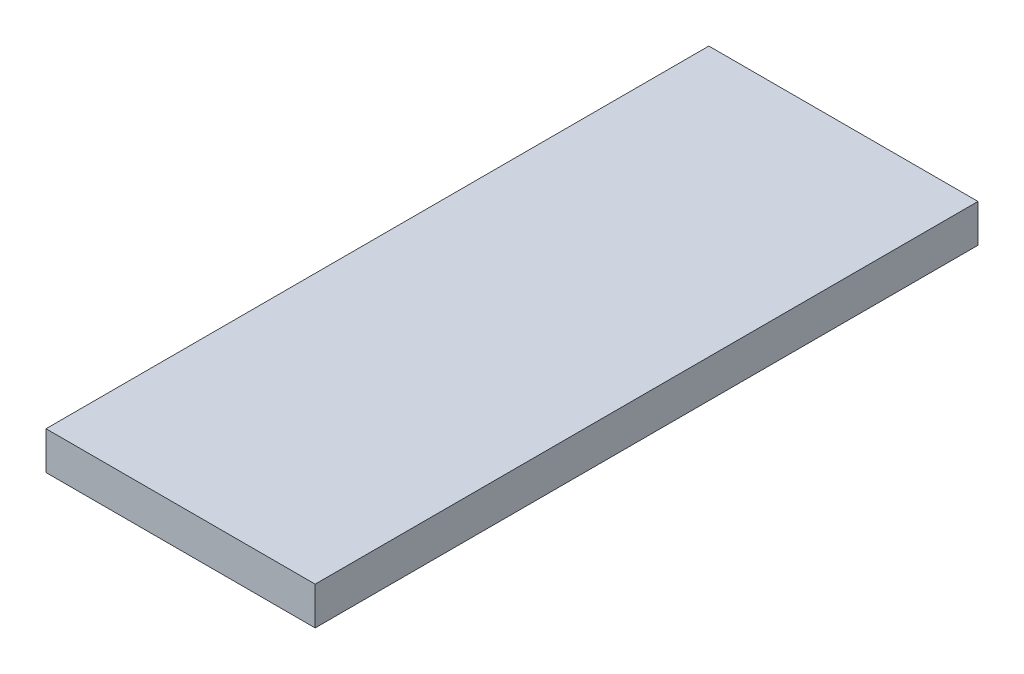
from build123d import *

# Parameters (mm, degrees)
SKETCH1_W           = 18.0086
SKETCH1_H           = 44.3484
BOSS_EXTRUDE1_DEPTH = 2.54


with BuildPart() as part:
    # Sketch1 → Boss-Extrude1 (new body)
    with BuildSketch(Plane(origin=(0, 0, 0), x_dir=(1, 0, 0), z_dir=(0, 1, 0))):
        with Locations((9.0043, 22.1742)):
            Rectangle(SKETCH1_W, SKETCH1_H)
    extrude(amount=BOSS_EXTRUDE1_DEPTH)


solid = part.part
